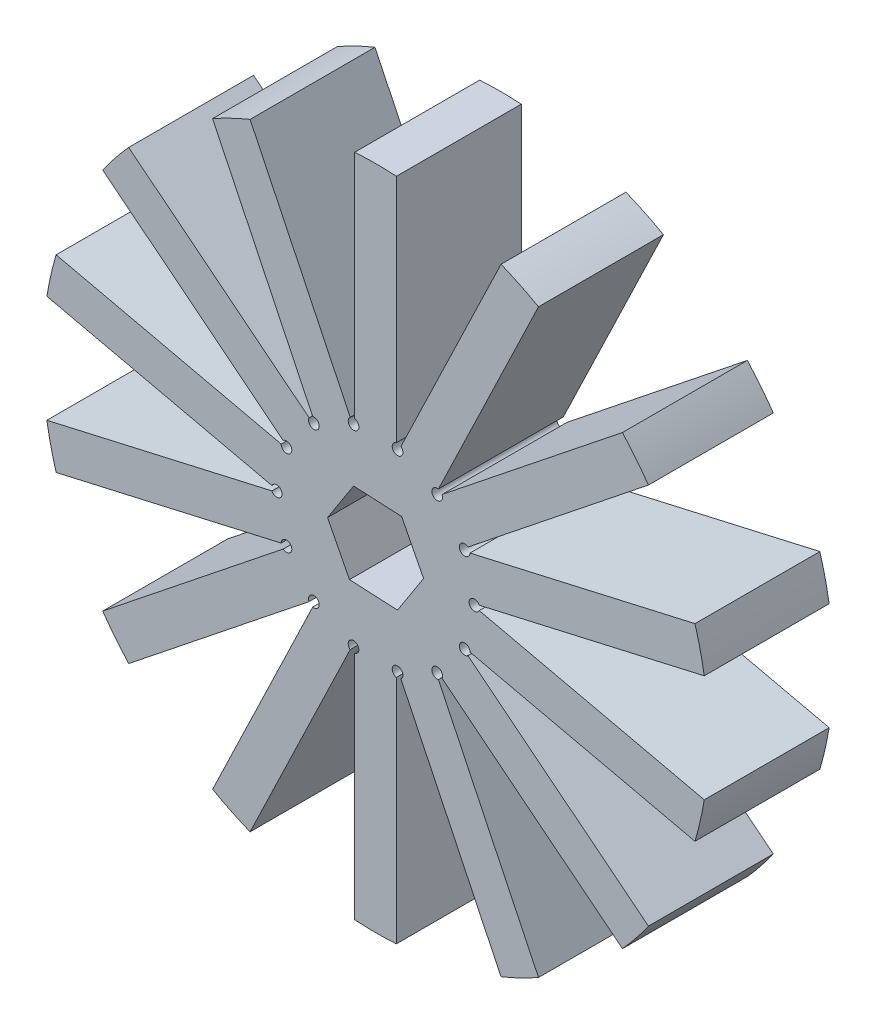
from build123d import *

# Parameters (mm, degrees)
BOSS_EXTRUDE1_DEPTH = 19.05


with BuildPart() as part:
    # Sketch1 → Boss-Extrude1 (new body)
    with BuildSketch(Plane.XY):
        with BuildLine():
            Line((-68.348679847, 27.880791406), (-34.028682265, 20.047475917))
            ThreePointArc((-34.028682265, 20.047475917), (-32.480984204, 19.694223934), (-34.028682265, 19.340971952))
            Line((-34.028682265, 19.340971952), (-68.348679847, 11.507656462))
            ThreePointArc((-68.348679847, 11.507656462), (-67.739001659, 8.390160489), (-66.935671916, 5.31686422))
            Line((-66.935671916, 5.31686422), (-32.615674334, 13.150179709))
            ThreePointArc((-32.615674334, 13.150179709), (-31.067976273, 13.503431692), (-32.309133752, 12.513641632))
            Line((-32.309133752, 12.513641632), (-59.831634906, -9.434820634))
            ThreePointArc((-59.831634906, -9.434820634), (-57.92970303, -11.979058), (-55.872474664, -14.399450548))
            Line((-55.872474664, -14.399450548), (-28.34997351, 7.549011718))
            ThreePointArc((-28.34997351, 7.549011718), (-27.108816032, 8.538801778), (-27.797606467, 7.1085137))
            Line((-27.797606467, 7.1085137), (-43.071442298, -24.60793321))
            ThreePointArc((-43.071442298, -24.60793321), (-40.253957668, -26.074994555), (-37.350289987, -27.363094953))
            Line((-37.350289987, -27.363094953), (-22.076454156, 4.353351957))
            ThreePointArc((-22.076454156, 4.353351957), (-21.38766372, 5.783640035), (-21.38766372, 4.196140035))
            Line((-21.38766372, 4.196140035), (-21.38766372, -31.006460233))
            ThreePointArc((-21.38766372, -31.006460233), (-18.21266372, -31.105776066), (-15.03766372, -31.006460233))
            Line((-15.03766372, -31.006460233), (-15.03766372, 4.196140035))
            ThreePointArc((-15.03766372, 4.196140035), (-15.03766372, 5.783640035), (-14.348873285, 4.353351957))
            Line((-14.348873285, 4.353351957), (0.924962546, -27.363094953))
            ThreePointArc((0.924962546, -27.363094953), (3.828630227, -26.074994555), (6.646114857, -24.60793321))
            Line((6.646114857, -24.60793321), (-8.627720973, 7.1085137))
            ThreePointArc((-8.627720973, 7.1085137), (-9.316511409, 8.538801778), (-8.075353931, 7.549011718))
            Line((-8.075353931, 7.549011718), (19.447147223, -14.399450548))
            ThreePointArc((19.447147223, -14.399450548), (21.504375589, -11.979058), (23.406307465, -9.434820634))
            Line((23.406307465, -9.434820634), (-4.116193689, 12.513641632))
            ThreePointArc((-4.116193689, 12.513641632), (-5.357351167, 13.503431692), (-3.809653107, 13.150179709))
            Line((-3.809653107, 13.150179709), (30.510344475, 5.31686422))
            ThreePointArc((30.510344475, 5.31686422), (31.313674218, 8.390160489), (31.923352406, 11.507656462))
            Line((31.923352406, 11.507656462), (-2.396645176, 19.340971952))
            ThreePointArc((-2.396645176, 19.340971952), (-3.944343237, 19.694223934), (-2.396645176, 20.047475917))
            Line((-2.396645176, 20.047475917), (31.923352406, 27.880791406))
            ThreePointArc((31.923352406, 27.880791406), (31.313674218, 30.998287379), (30.510344475, 34.071583649))
            Line((30.510344475, 34.071583649), (-3.809653107, 26.238268159))
            ThreePointArc((-3.809653107, 26.238268159), (-5.357351167, 25.885016177), (-4.116193689, 26.874806237))
            Line((-4.116193689, 26.874806237), (23.406307465, 48.823268503))
            ThreePointArc((23.406307465, 48.823268503), (21.504375589, 51.367505869), (19.447147223, 53.787898417))
            Line((19.447147223, 53.787898417), (-8.075353931, 31.839436151))
            ThreePointArc((-8.075353931, 31.839436151), (-9.316511409, 30.84964609), (-8.627720973, 32.279934168))
            Line((-8.627720973, 32.279934168), (6.646114857, 63.996381078))
            ThreePointArc((6.646114857, 63.996381078), (3.828630227, 65.463442424), (0.924962546, 66.751542822))
            Line((0.924962546, 66.751542822), (-14.348873285, 35.035095912))
            ThreePointArc((-14.348873285, 35.035095912), (-15.03766372, 33.604807834), (-15.03766372, 35.192307834))
            Line((-15.03766372, 35.192307834), (-15.03766372, 70.394908101))
            ThreePointArc((-15.03766372, 70.394908101), (-18.21266372, 70.494223934), (-21.38766372, 70.394908101))
            Line((-21.38766372, 70.394908101), (-21.38766372, 35.192307834))
            ThreePointArc((-21.38766372, 35.192307834), (-21.38766372, 33.604807834), (-22.076454156, 35.035095912))
            Line((-22.076454156, 35.035095912), (-37.350289987, 66.751542822))
            ThreePointArc((-37.350289987, 66.751542822), (-40.253957668, 65.463442424), (-43.071442298, 63.996381078))
            Line((-43.071442298, 63.996381078), (-27.797606467, 32.279934168))
            ThreePointArc((-27.797606467, 32.279934168), (-27.108816032, 30.84964609), (-28.34997351, 31.839436151))
            Line((-28.34997351, 31.839436151), (-55.872474664, 53.787898417))
            ThreePointArc((-55.872474664, 53.787898417), (-57.92970303, 51.367505869), (-59.831634906, 48.823268503))
            Line((-59.831634906, 48.823268503), (-32.309133752, 26.874806237))
            ThreePointArc((-32.309133752, 26.874806237), (-31.067976273, 25.885016177), (-32.615674334, 26.238268159))
            Line((-32.615674334, 26.238268159), (-66.935671916, 34.071583649))
            ThreePointArc((-66.935671916, 34.071583649), (-67.739001659, 30.998287379), (-68.348679847, 27.880791406))
        make_face()
        Polygon((-10.889375563, 19.329828678), (-14.866595191, 13.169872723), (-22.189883348, 13.534267979), (-25.535951877, 20.05861919), (-21.55873225, 26.218575146), (-14.235444093, 25.854179889), align=None, mode=Mode.SUBTRACT)
    extrude(amount=BOSS_EXTRUDE1_DEPTH)


solid = part.part
